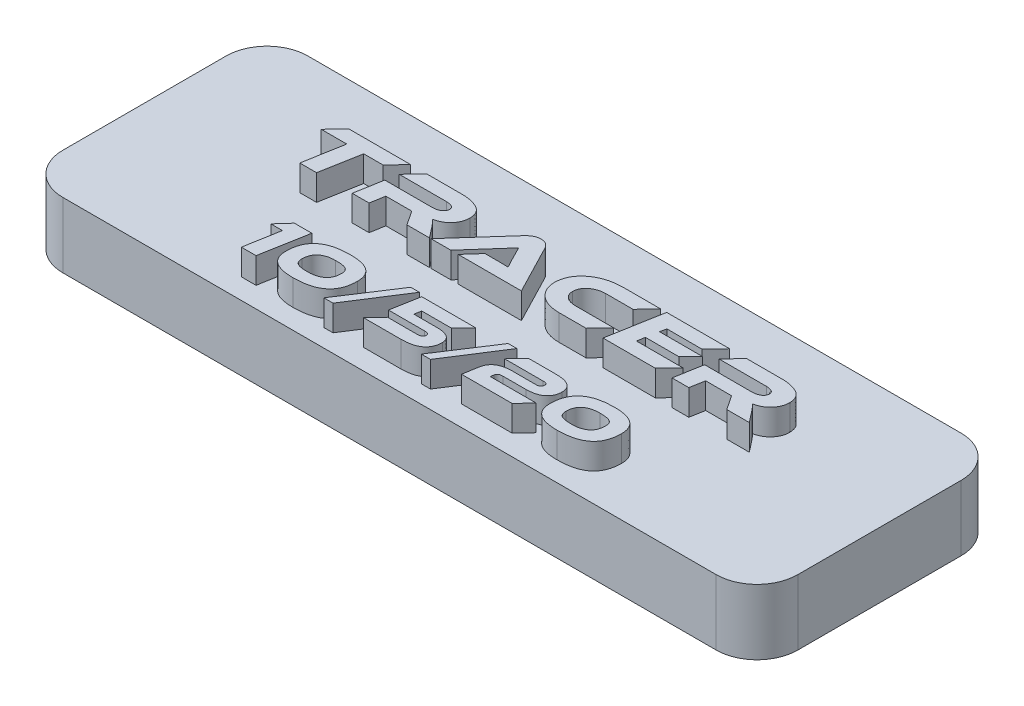
from build123d import *

# Parameters (mm, degrees)
SKETCH1_W           = 57.15
SKETCH1_H           = 19.05
BOSS_EXTRUDE1_DEPTH = 5.08
FILLET1_R           = 3.175
BOSS_EXTRUDE2_DEPTH = 2
SKETCH4_R           = 0.9
CUT_EXTRUDE1_DEPTH  = 4


with BuildPart() as part:
    # Sketch1 → Boss-Extrude1 (new body)
    with BuildSketch(Plane(origin=(0, 0, 0), x_dir=(1, 0, 0), z_dir=(0, 1, 0))):
        Rectangle(SKETCH1_W, SKETCH1_H)
    extrude(amount=BOSS_EXTRUDE1_DEPTH)

    # Fillet1
    fillet1_edges = [part.edges().sort_by_distance(p)[0] for p in [
        (-28.575, 2.54, -9.525),
        (-28.575, 2.54, 9.525),
        (28.575, 2.54, 9.525),
        (28.575, 2.54, -9.525),
    ]]
    fillet(fillet1_edges, radius=FILLET1_R)

    # Sketch3 → Boss-Extrude2 (add)
    with BuildSketch(Plane(origin=(0, 5.08, 0), x_dir=(1, 0, 0), z_dir=(0, 1, 0))):
        with BuildLine():
            add(Edge.make_bspline(
                [(17.808583065, 0.821261664), (17.780796939, 0.855514425), (17.727887369, 0.920737585), (17.654102028, 1.014147602), (17.585498843, 1.094728322), (17.525132752, 1.165931133), (17.469151617, 1.228233858), (17.417647241, 1.283693514), (17.369064358, 1.332710365), (17.336760483, 1.361916294), (17.321401159, 1.375802657)],
                knots=[0, 0, 0, 0, 0.000132319, 0.000251958, 0.000357066, 0.000449775, 0.000531993, 0.000608312, 0.000676831, 0.00073894, 0.00073894, 0.00073894, 0.00073894], degree=3))
            add(Edge.make_bspline(
                [(17.321401159, 1.375802657), (17.371846082, 1.387655917), (17.471178792, 1.41099655), (17.615145812, 1.456505146), (17.750984544, 1.512656797), (17.878954086, 1.577599655), (17.999740692, 1.650662326), (18.111465112, 1.734287933), (18.215202991, 1.827209607), (18.310758459, 1.928008098), (18.396625274, 2.036209783), (18.472838882, 2.148795776), (18.536085152, 2.26744033), (18.589751097, 2.389702633), (18.630253479, 2.517720245), (18.662407259, 2.649747841), (18.680016954, 2.787111939), (18.684148398, 2.88015474), (18.686233961, 2.927122995)],
                knots=[0, 0, 0, 0, 0.000155422, 0.000306047, 0.000452383, 0.000595882, 0.000736201, 0.000875336, 0.001013884, 0.001153561, 0.001291475, 0.00142788, 0.00156081, 0.001694289, 0.00182785, 0.001963107, 0.002101444, 0.002242464, 0.002242464, 0.002242464, 0.002242464], degree=3))
            add(Edge.make_bspline(
                [(18.686233961, 2.927122995), (18.681570314, 2.986733362), (18.672571354, 3.101757358), (18.636165187, 3.266295736), (18.583579546, 3.416602664), (18.512618081, 3.55250609), (18.424089862, 3.674215745), (18.316288118, 3.779555576), (18.192942579, 3.872802597), (18.05131082, 3.946152329), (17.901517173, 4.009923214), (17.747227802, 4.066098529), (17.589109987, 4.111445148), (17.428122354, 4.149301444), (17.263555019, 4.17747869), (17.09601278, 4.196572697), (16.925405287, 4.207081738), (16.810706728, 4.20637971), (16.752797005, 4.206025266)],
                knots=[0, 0, 0, 0, 0.000179195, 0.000345775, 0.000503934, 0.000655634, 0.000804102, 0.000953423, 0.00110627, 0.001266195, 0.001430402, 0.00159465, 0.001758393, 0.001923592, 0.002090563, 0.002258951, 0.002429281, 0.002602973, 0.002602973, 0.002602973, 0.002602973], degree=3))
            Line((16.752797005, 4.206025266), (14.03629737, 4.206347541))
            Line((14.03629737, 4.206347541), (12.987387109, 3.106887389))
            Line((12.987387109, 3.106887389), (16.664891757, 3.106887389))
            add(Edge.make_bspline(
                [(16.664891757, 3.106887389), (16.712853307, 3.105563142), (16.803665063, 3.103055777), (16.931769874, 3.084102014), (17.043390167, 3.053127658), (17.13774974, 3.008361144), (17.213916059, 2.950733271), (17.269652471, 2.878524615), (17.302879134, 2.792039639), (17.306644482, 2.729960255), (17.308602995, 2.697670193)],
                knots=[0, 0, 0, 0, 0.000143839, 0.000272348, 0.000387495, 0.000490117, 0.000583924, 0.00067132, 0.000760449, 0.00085706, 0.00085706, 0.00085706, 0.00085706], degree=3))
            add(Edge.make_bspline(
                [(17.308602995, 2.697670193), (17.306925955, 2.677195647), (17.303617965, 2.636809238), (17.290836727, 2.578009425), (17.270728249, 2.522994029), (17.243337309, 2.47158108), (17.209945932, 2.423095084), (17.168008998, 2.378841184), (17.118990862, 2.338813063), (17.045312647, 2.288346001), (16.940698269, 2.236864834), (16.803219092, 2.191707585), (16.652613655, 2.165412454), (16.54812873, 2.161339559), (16.494091256, 2.15923314)],
                knots=[0, 0, 0, 0, 6.1582e-05, 0.000121471, 0.000179891, 0.000236731, 0.000295819, 0.000355966, 0.000418937, 0.000485369, 0.000623551, 0.000766937, 0.000918284, 0.001080402, 0.001080402, 0.001080402, 0.001080402], degree=3))
            Line((16.494091256, 2.15923314), (12.816781224, 2.159459893))
            Line((12.816781224, 2.159459893), (12.437657033, 0.003655726))
            Line((12.437657033, 0.003655726), (13.74563549, 0.003655726))
            Line((13.74563549, 0.003655726), (13.941516322, 1.11686837))
            Line((13.941516322, 1.11686837), (15.950874531, 1.11686837))
            Line((15.950874531, 1.11686837), (16.696485439, 0.003655726))
            Line((16.696485439, 0.003655726), (18.446775452, 0.003655726))
            Line((18.446775452, 0.003655726), (17.808583065, 0.821261664))
        make_face()
        Polygon((8.571611573, 1.105536066), (8.672711357, 1.700326644), (11.276030798, 1.700326644), (12.185928855, 2.629107706), (8.843317243, 2.629107706), (8.931779554, 3.106887389), (11.667792461, 3.106887389), (12.710383985, 4.206347541), (7.819681928, 4.206347541), (7.067752284, 0.006075914), (11.137018595, 0.006075914), (12.173291382, 1.105536066), align=None)
        with BuildLine():
            add(Edge.make_bspline(
                [(3.820482353, 1.105536066), (3.780761323, 1.106368572), (3.703345841, 1.107991107), (3.590518754, 1.120099472), (3.484273761, 1.139341634), (3.383862171, 1.164731953), (3.289329261, 1.197730851), (3.200819168, 1.237674392), (3.118521578, 1.284870974), (3.042716275, 1.338214411), (2.975245037, 1.398892985), (2.915259867, 1.463686553), (2.864502207, 1.534061863), (2.822018426, 1.609307897), (2.789181432, 1.690172386), (2.765369619, 1.775740301), (2.750595998, 1.866215268), (2.747636192, 1.928202108), (2.746120386, 1.95994744)],
                knots=[0, 0, 0, 0, 0.000119146, 0.000232213, 0.000339979, 0.000442857, 0.0005426, 0.00063997, 0.000733741, 0.000826832, 0.000917476, 0.001005473, 0.001091233, 0.001177183, 0.0012641, 0.001352376, 0.001443149, 0.001538437, 0.001538437, 0.001538437, 0.001538437], degree=3))
            add(Edge.make_bspline(
                [(2.746120386, 1.95994744), (2.748498007, 2.00089212), (2.753181944, 2.08155355), (2.776941296, 2.199187811), (2.811422163, 2.311187764), (2.858398604, 2.41754111), (2.918527204, 2.517456178), (2.989951472, 2.612420697), (3.075122499, 2.700160835), (3.170482644, 2.782047564), (3.275509773, 2.855559397), (3.386992271, 2.920673089), (3.504905177, 2.975739929), (3.628515938, 3.021270473), (3.757976585, 3.058247704), (3.893480191, 3.084423964), (4.034988181, 3.10108536), (4.131324183, 3.104537604), (4.180428937, 3.106297295)],
                knots=[0, 0, 0, 0, 0.000122909, 0.000242131, 0.000358943, 0.000473945, 0.00058996, 0.00070807, 0.000829622, 0.000956043, 0.00108463, 0.001213669, 0.001342898, 0.001474501, 0.001608483, 0.001746351, 0.001888089, 0.00203545, 0.00203545, 0.00203545, 0.00203545], degree=3))
            Line((4.180428937, 3.106297295), (6.3037458, 3.106887389))
            Line((6.3037458, 3.106887389), (7.340018588, 4.206347541))
            Line((7.340018588, 4.206347541), (4.376531166, 4.206347541))
            add(Edge.make_bspline(
                [(4.376531166, 4.206347541), (4.274511376, 4.202700375), (4.0747035, 4.195557324), (3.781487586, 4.162353327), (3.50135048, 4.110015155), (3.234489531, 4.036172143), (2.979880771, 3.945267581), (2.73875412, 3.833094278), (2.51011283, 3.702119343), (2.331200298, 3.576781715), (2.195666357, 3.469194079), (2.101588733, 3.383435035), (2.012759192, 3.295964452), (1.929960056, 3.205335074), (1.854457159, 3.110727377), (1.783271377, 3.01426649), (1.720732933, 2.913020304), (1.66256647, 2.809716549), (1.611371146, 2.702914965), (1.567527882, 2.592415367), (1.529369475, 2.479140843), (1.495826369, 2.363167205), (1.470866325, 2.243547853), (1.450168152, 2.121372678), (1.437733491, 1.99550854), (1.433639078, 1.910604524), (1.431566087, 1.867617826)],
                knots=[0, 0, 0, 0, 0.000306166, 0.000599632, 0.000884344, 0.001160233, 0.001429449, 0.00169448, 0.001956971, 0.002218938, 0.002348999, 0.002475859, 0.002600617, 0.002722926, 0.00284385, 0.002963619, 0.003082322, 0.003200591, 0.003319167, 0.003437316, 0.003556997, 0.003677669, 0.003799234, 0.003923371, 0.004049262, 0.004178365, 0.004178365, 0.004178365, 0.004178365], degree=3))
            add(Edge.make_bspline(
                [(1.431566087, 1.867617826), (1.43456596, 1.801688472), (1.44047092, 1.671912941), (1.470921427, 1.482185543), (1.519574542, 1.301387781), (1.586380821, 1.130003576), (1.671389099, 0.967607666), (1.773923148, 0.814264123), (1.896175404, 0.671011828), (2.034406672, 0.536982875), (2.188663177, 0.415938203), (2.356222568, 0.308972587), (2.536928442, 0.218224767), (2.731158345, 0.144692398), (2.937328223, 0.084618858), (3.157163123, 0.042789332), (3.389231358, 0.013380635), (3.548654609, 0.00815489), (3.630107874, 0.005484928)],
                knots=[0, 0, 0, 0, 0.000197872, 0.000389491, 0.000575101, 0.000758611, 0.000940158, 0.001123976, 0.001310786, 0.001504088, 0.001700684, 0.001897981, 0.00209953, 0.002306142, 0.002520237, 0.002742905, 0.002976823, 0.003221191, 0.003221191, 0.003221191, 0.003221191], degree=3))
            Line((3.630107874, 0.005484928), (5.754015724, 0.006075914))
            Line((5.754015724, 0.006075914), (6.783969775, 1.105536066))
            Line((6.783969775, 1.105536066), (3.820482353, 1.105536066))
        make_face()
        with BuildLine():
            Line((0.725117419, 0.006075914), (-1.240009635, 3.800574494))
            add(Edge.make_bspline(
                [(-1.240009635, 3.800574494), (-1.258130579, 3.832806008), (-1.294089242, 3.896765269), (-1.358962932, 3.985575321), (-1.436222419, 4.0630874), (-1.521125331, 4.133983071), (-1.618931224, 4.192399523), (-1.731042374, 4.23493807), (-1.857084201, 4.260058315), (-1.945815134, 4.264204191), (-1.99194285, 4.266359469)],
                knots=[0, 0, 0, 0, 0.000110886, 0.000220038, 0.000328642, 0.000438436, 0.000551159, 0.000668641, 0.000796469, 0.000934872, 0.000934872, 0.000934872, 0.000934872], degree=3))
            add(Edge.make_bspline(
                [(-1.99194285, 4.266359469), (-2.04175451, 4.264009128), (-2.138485631, 4.259444915), (-2.278524387, 4.230967468), (-2.408802949, 4.187726952), (-2.528537824, 4.126959855), (-2.638219479, 4.055096369), (-2.741420833, 3.977511138), (-2.835727046, 3.892229282), (-2.893109549, 3.830720556), (-2.921638068, 3.800140628)],
                knots=[0, 0, 0, 0, 0.00014941, 0.000290146, 0.000427171, 0.000560039, 0.000691642, 0.000820174, 0.000947034, 0.001072464, 0.001072464, 0.001072464, 0.001072464], degree=3))
            Line((-2.921638068, 3.800140628), (-6.307636314, 0.006075914))
            Line((-6.307636314, 0.006075914), (-4.75954587, 0.006075914))
            Line((-4.75954587, 0.006075914), (-2.282601159, 2.798493231))
            Line((-2.282601159, 2.798493231), (-1.72023361, 1.696826253))
            add(Edge.make_bspline(
                [(-1.72023361, 1.696826253), (-1.693559605, 1.644325557), (-1.639043358, 1.5370248), (-1.569615017, 1.403208105), (-1.513531922, 1.297464771), (-1.472390808, 1.223921613), (-1.435986966, 1.155498073), (-1.410688661, 1.112747401), (-1.398656522, 1.092414734)],
                knots=[0, 0, 0, 0, 0.000176664, 0.000361065, 0.000452265, 0.000535729, 0.000613867, 0.000684736, 0.000684736, 0.000684736, 0.000684736], degree=3))
            add(Edge.make_bspline(
                [(-1.398656522, 1.092414734), (-1.454104866, 1.095166522), (-1.572264702, 1.101030553), (-1.756695237, 1.103502684), (-1.951714103, 1.10564963), (-2.0839667, 1.105358474), (-2.150091594, 1.105212899)],
                knots=[0, 0, 0, 0, 0.000166537, 0.000354888, 0.000553268, 0.00075164, 0.00075164, 0.00075164, 0.00075164], degree=3))
            Line((-2.150091594, 1.105212899), (-3.205136689, 1.105536066))
            Line((-3.205136689, 1.105536066), (-4.190859584, 0.006075914))
            Line((-4.190859584, 0.006075914), (0.725117419, 0.006075914))
        make_face()
        with BuildLine():
            add(Edge.make_bspline(
                [(-7.056421766, 0.821261664), (-7.084207891, 0.855514425), (-7.137117462, 0.920737585), (-7.210902803, 1.014147602), (-7.279505988, 1.094728322), (-7.339872079, 1.165931133), (-7.395853214, 1.228233858), (-7.44735759, 1.283693514), (-7.495940473, 1.332710365), (-7.528244348, 1.361916294), (-7.543603671, 1.375802657)],
                knots=[0, 0, 0, 0, 0.000132319, 0.000251958, 0.000357066, 0.000449775, 0.000531993, 0.000608312, 0.000676831, 0.00073894, 0.00073894, 0.00073894, 0.00073894], degree=3))
            add(Edge.make_bspline(
                [(-7.543603671, 1.375802657), (-7.493158749, 1.387655917), (-7.393826039, 1.41099655), (-7.249859019, 1.456505146), (-7.114020287, 1.512656797), (-6.986050744, 1.577599655), (-6.865264138, 1.650662326), (-6.753539719, 1.734287933), (-6.649801839, 1.827209607), (-6.554246372, 1.928008098), (-6.468379557, 2.036209783), (-6.392165949, 2.148795776), (-6.328919679, 2.26744033), (-6.275253734, 2.389702633), (-6.234751352, 2.517720245), (-6.202597572, 2.649747841), (-6.184987877, 2.787111939), (-6.180856433, 2.88015474), (-6.17877087, 2.927122995)],
                knots=[0, 0, 0, 0, 0.000155422, 0.000306047, 0.000452383, 0.000595882, 0.000736201, 0.000875336, 0.001013884, 0.001153561, 0.001291475, 0.00142788, 0.00156081, 0.001694289, 0.00182785, 0.001963107, 0.002101444, 0.002242464, 0.002242464, 0.002242464, 0.002242464], degree=3))
            add(Edge.make_bspline(
                [(-6.17877087, 2.927122995), (-6.183434517, 2.986733362), (-6.192433477, 3.101757358), (-6.228839644, 3.266295736), (-6.281425285, 3.416602664), (-6.35238675, 3.55250609), (-6.440914969, 3.674215745), (-6.548716712, 3.779555576), (-6.672062252, 3.872802597), (-6.813694011, 3.946152329), (-6.963487658, 4.009923214), (-7.117777029, 4.066098529), (-7.275894844, 4.111445148), (-7.436882477, 4.149301444), (-7.601449812, 4.17747869), (-7.768992051, 4.196572697), (-7.939599544, 4.207081738), (-8.054298103, 4.20637971), (-8.112207826, 4.206025266)],
                knots=[0, 0, 0, 0, 0.000179195, 0.000345775, 0.000503934, 0.000655634, 0.000804102, 0.000953423, 0.00110627, 0.001266195, 0.001430402, 0.00159465, 0.001758393, 0.001923592, 0.002090563, 0.002258951, 0.002429281, 0.002602973, 0.002602973, 0.002602973, 0.002602973], degree=3))
            Line((-8.112207826, 4.206025266), (-10.828707461, 4.206347541))
            Line((-10.828707461, 4.206347541), (-11.877617722, 3.106887389))
            Line((-11.877617722, 3.106887389), (-8.200113074, 3.106887389))
            add(Edge.make_bspline(
                [(-8.200113074, 3.106887389), (-8.152151524, 3.105563142), (-8.061339768, 3.103055777), (-7.933234957, 3.084102014), (-7.821614664, 3.053127658), (-7.727255091, 3.008361144), (-7.651088772, 2.950733271), (-7.59535236, 2.878524615), (-7.562125697, 2.792039639), (-7.558360349, 2.729960255), (-7.556401836, 2.697670193)],
                knots=[0, 0, 0, 0, 0.000143839, 0.000272348, 0.000387495, 0.000490117, 0.000583924, 0.00067132, 0.000760449, 0.00085706, 0.00085706, 0.00085706, 0.00085706], degree=3))
            add(Edge.make_bspline(
                [(-7.556401836, 2.697670193), (-7.558078875, 2.677195647), (-7.561386866, 2.636809238), (-7.574168104, 2.578009425), (-7.594276582, 2.522994029), (-7.621667522, 2.47158108), (-7.655058899, 2.423095084), (-7.696995833, 2.378841184), (-7.746013969, 2.338813063), (-7.819692184, 2.288346001), (-7.924306562, 2.236864834), (-8.061785739, 2.191707585), (-8.212391176, 2.165412454), (-8.316876101, 2.161339559), (-8.370913575, 2.15923314)],
                knots=[0, 0, 0, 0, 6.1582e-05, 0.000121471, 0.000179891, 0.000236731, 0.000295819, 0.000355966, 0.000418937, 0.000485369, 0.000623551, 0.000766937, 0.000918284, 0.001080402, 0.001080402, 0.001080402, 0.001080402], degree=3))
            Line((-8.370913575, 2.15923314), (-12.048223607, 2.159459893))
            Line((-12.048223607, 2.159459893), (-12.427347798, 0.003655726))
            Line((-12.427347798, 0.003655726), (-11.119369341, 0.003655726))
            Line((-11.119369341, 0.003655726), (-10.923488509, 1.11686837))
            Line((-10.923488509, 1.11686837), (-8.9141303, 1.11686837))
            Line((-8.9141303, 1.11686837), (-8.168519392, 0.003655726))
            Line((-8.168519392, 0.003655726), (-6.418229379, 0.003655726))
            Line((-6.418229379, 0.003655726), (-7.056421766, 0.821261664))
        make_face()
        Polygon((-16.889222079, 4.206347541), (-17.938132339, 3.106887389), (-15.954049076, 3.106887389), (-16.503779152, 0.003655726), (-15.195800695, 0.003655726), (-14.639751882, 3.106887389), (-13.135892594, 3.106887389), (-12.086982333, 4.206347541), align=None)
        with BuildLine():
            add(Edge.make_bspline(
                [(12.169570041, -4.205753245), (12.112468685, -4.20639815), (12.000136614, -4.207666832), (11.834425188, -4.213805403), (11.674414401, -4.225246011), (11.519900797, -4.240095428), (11.37100602, -4.260037206), (11.227788675, -4.284920981), (11.089877095, -4.313802188), (10.957328068, -4.346120038), (10.830514159, -4.383749272), (10.709576932, -4.426552533), (10.593554301, -4.472224962), (10.483700027, -4.524117338), (10.378631334, -4.578873484), (10.279615039, -4.638857599), (10.186140404, -4.703243715), (10.098326394, -4.771965987), (10.015468161, -4.844826576), (9.93847452, -4.922821718), (9.866909556, -5.005043307), (9.799499924, -5.090962924), (9.739391164, -5.18251662), (9.682799293, -5.277290921), (9.633633224, -5.377585075), (9.587505253, -5.480915677), (9.548631627, -5.589719203), (9.51425091, -5.702636581), (9.484439908, -5.819692193), (9.461584956, -5.941608197), (9.442985816, -6.06752364), (9.430676969, -6.198094357), (9.422126321, -6.332815699), (9.421411865, -6.424102975), (9.421048659, -6.470510423)],
                knots=[0, 0, 0, 0, 0.000171312, 0.000337012, 0.00049738, 0.000652505, 0.000802621, 0.000947932, 0.001088493, 0.001225264, 0.001357119, 0.001485126, 0.001610044, 0.001730996, 0.001849428, 0.001965345, 0.002078058, 0.002189744, 0.002299681, 0.002408844, 0.002518253, 0.002626572, 0.002736165, 0.002846598, 0.002957491, 0.003071033, 0.00318591, 0.003303822, 0.003425073, 0.003548063, 0.003675777, 0.003806785, 0.003941403, 0.004080604, 0.004080604, 0.004080604, 0.004080604], degree=3))
            add(Edge.make_bspline(
                [(9.421048659, -6.470510423), (9.422406313, -6.532725476), (9.425040053, -6.653417738), (9.450427175, -6.827938058), (9.490950393, -6.990047106), (9.547744772, -7.14024227), (9.621690482, -7.277956037), (9.712251074, -7.403136721), (9.818581385, -7.515956622), (9.941638938, -7.616000774), (10.081125233, -7.702745849), (10.235745057, -7.779438213), (10.4068577, -7.842507446), (10.593416255, -7.895609169), (10.796231665, -7.935791135), (11.014812544, -7.964127031), (11.249321424, -7.98091947), (11.410868163, -7.982880129), (11.494351268, -7.983893345)],
                knots=[0, 0, 0, 0, 0.000186545, 0.000361882, 0.000527754, 0.000687003, 0.000842323, 0.000995285, 0.001149196, 0.001306104, 0.001469661, 0.00164101, 0.001823006, 0.002015943, 0.002222385, 0.002442644, 0.002676813, 0.00292724, 0.00292724, 0.00292724, 0.00292724], degree=3))
            add(Edge.make_bspline(
                [(11.494351268, -7.983893345), (11.551148832, -7.983380019), (11.662646901, -7.98237232), (11.827237734, -7.975990544), (11.986252389, -7.965003258), (12.140107772, -7.948680913), (12.288559713, -7.929266178), (12.431198679, -7.904105738), (12.568465429, -7.875596387), (12.699967043, -7.841995411), (12.826316296, -7.804464931), (12.946853278, -7.761989808), (13.062391555, -7.715814846), (13.172186892, -7.664606669), (13.276164902, -7.608490903), (13.37508354, -7.548339608), (13.468456356, -7.483895632), (13.556165684, -7.414499954), (13.638570533, -7.341424669), (13.714571424, -7.262809113), (13.787160107, -7.18190029), (13.852689263, -7.094705032), (13.913367614, -7.003516426), (13.96977868, -6.908219643), (14.019940881, -6.808134503), (14.064878604, -6.703993625), (14.103970066, -6.595424725), (14.138640351, -6.482622195), (14.166962367, -6.364960314), (14.191198475, -6.243348255), (14.209604428, -6.117331748), (14.221979441, -5.986773695), (14.230455362, -5.851777937), (14.231187523, -5.760225753), (14.231558647, -5.713818961)],
                knots=[0, 0, 0, 0, 0.000170392, 0.000334494, 0.000494064, 0.000648473, 0.00079859, 0.000943113, 0.001082891, 0.001219081, 0.001350169, 0.001478176, 0.001602352, 0.001723304, 0.001841405, 0.001956639, 0.002070464, 0.002181522, 0.00229199, 0.002400592, 0.0025094, 0.002617866, 0.002727459, 0.002837893, 0.002949859, 0.003063082, 0.00317796, 0.003295871, 0.003416929, 0.003540857, 0.00366778, 0.003798788, 0.003934205, 0.004073405, 0.004073405, 0.004073405, 0.004073405], degree=3))
            add(Edge.make_bspline(
                [(14.231558647, -5.713818961), (14.230216992, -5.651864372), (14.227608861, -5.53142685), (14.201896297, -5.357329546), (14.162708811, -5.194951682), (14.105683344, -5.045253766), (14.032315227, -4.907894424), (13.943060126, -4.782830639), (13.83695532, -4.670804764), (13.715334516, -4.570938519), (13.576786406, -4.484275151), (13.422596711, -4.409545186), (13.252718506, -4.345204255), (13.066791105, -4.293863202), (12.864859935, -4.25419887), (12.6473983, -4.225768444), (12.413684659, -4.209016704), (12.252670788, -4.207051109), (12.169570041, -4.205753245)],
                knots=[0, 0, 0, 0, 0.000185746, 0.000361083, 0.00052676, 0.000686009, 0.000840246, 0.000992741, 0.001145521, 0.00130181, 0.001463587, 0.001634583, 0.001815083, 0.002007802, 0.002212518, 0.002431984, 0.002665356, 0.002914983, 0.002914983, 0.002914983, 0.002914983], degree=3))
        make_face()
        with BuildLine():
            add(Edge.make_bspline(
                [(11.660911752, -7.021348599), (11.614718672, -7.021854174), (11.525564137, -7.022829956), (11.396649142, -7.017591194), (11.277303679, -7.009340097), (11.16754258, -6.995853431), (11.067278538, -6.977791428), (10.976735205, -6.954558851), (10.89539598, -6.92776808), (10.823188164, -6.89577873), (10.759196802, -6.85746675), (10.705170231, -6.809228041), (10.658600519, -6.753532905), (10.622050208, -6.688452997), (10.592915143, -6.615916979), (10.573454339, -6.534816355), (10.561142184, -6.445830998), (10.56044659, -6.383634321), (10.560085278, -6.351327518)],
                knots=[0, 0, 0, 0, 0.000138565, 0.000267436, 0.000386943, 0.000497368, 0.000599032, 0.000692348, 0.000777591, 0.00085564, 0.000928899, 0.001000308, 0.001071897, 0.001145712, 0.001223247, 0.001305698, 0.001395292, 0.001492131, 0.001492131, 0.001492131, 0.001492131], degree=3))
            add(Edge.make_bspline(
                [(10.560085278, -6.351327518), (10.561622131, -6.304070169), (10.564612218, -6.212126705), (10.583274158, -6.079013736), (10.612529601, -5.954439253), (10.65434742, -5.839274516), (10.706405048, -5.731825667), (10.77161527, -5.634468641), (10.84743114, -5.545120744), (10.935376687, -5.466071948), (11.033349763, -5.395226287), (11.141952241, -5.334487382), (11.260332776, -5.283435533), (11.387926383, -5.240941797), (11.525259354, -5.208296683), (11.672129215, -5.185693562), (11.828663433, -5.170762309), (11.93638475, -5.169135367), (11.991879903, -5.16829721)],
                knots=[0, 0, 0, 0, 0.000141763, 0.000275812, 0.0004025, 0.000524963, 0.000642655, 0.000759791, 0.000875529, 0.00099331, 0.001113634, 0.001237554, 0.001365798, 0.001499859, 0.001640517, 0.001788722, 0.001945363, 0.002111808, 0.002111808, 0.002111808, 0.002111808], degree=3))
            add(Edge.make_bspline(
                [(11.991879903, -5.16829721), (12.038008552, -5.168009724), (12.127086872, -5.167454564), (12.256237185, -5.171313587), (12.375848317, -5.17974049), (12.485785403, -5.193477036), (12.586078611, -5.210588071), (12.676790366, -5.232796313), (12.757984669, -5.25982086), (12.830269457, -5.291687778), (12.89389505, -5.330152418), (12.948290416, -5.377160874), (12.993877712, -5.432670471), (13.030802255, -5.496790682), (13.05965157, -5.569240936), (13.079078595, -5.650050065), (13.091514122, -5.738759012), (13.092176501, -5.80069376), (13.092522029, -5.833001866)],
                knots=[0, 0, 0, 0, 0.00013838, 0.000267224, 0.000387529, 0.000497953, 0.000599476, 0.000692596, 0.00077784, 0.000855889, 0.000929147, 0.001000031, 0.001070493, 0.001143616, 0.001221151, 0.001303602, 0.001392403, 0.001489242, 0.001489242, 0.001489242, 0.001489242], degree=3))
            add(Edge.make_bspline(
                [(13.092522029, -5.833001866), (13.090984509, -5.880258006), (13.087993125, -5.972199119), (13.06930429, -6.105585977), (13.039943341, -6.230260661), (12.999240676, -6.346409008), (12.946238519, -6.453739693), (12.880821257, -6.551573704), (12.805177247, -6.64153852), (12.717535247, -6.721564153), (12.6191203, -6.791879743), (12.511575415, -6.854243117), (12.393026077, -6.904835069), (12.265385944, -6.947243215), (12.128190771, -6.980841995), (11.981089207, -7.004512108), (11.824198458, -7.019068958), (11.716218827, -7.020761541), (11.660911752, -7.021348599)],
                knots=[0, 0, 0, 0, 0.000141763, 0.000275812, 0.000403278, 0.000525472, 0.000644235, 0.000761371, 0.000877718, 0.000996039, 0.001116363, 0.001239983, 0.001368227, 0.001502288, 0.001643134, 0.001791467, 0.001948904, 0.002115349, 0.002115349, 0.002115349, 0.002115349], degree=3))
        make_face(mode=Mode.SUBTRACT)
        with BuildLine():
            Line((4.638273756, -5.218973535), (7.62940565, -5.218973535))
            add(Edge.make_bspline(
                [(7.62940565, -5.218973535), (7.657106564, -5.218922741), (7.708952939, -5.218827674), (7.781681941, -5.225918073), (7.843205983, -5.242216387), (7.89503652, -5.26353583), (7.935129909, -5.294908436), (7.963443909, -5.334273792), (7.980995886, -5.381008794), (7.982220586, -5.4147712), (7.982854952, -5.432259348)],
                knots=[0, 0, 0, 0, 8.3099e-05, 0.000155531, 0.000218392, 0.000273538, 0.000322508, 0.000368908, 0.000417497, 0.000469711, 0.000469711, 0.000469711, 0.000469711], degree=3))
            add(Edge.make_bspline(
                [(7.982854952, -5.432259348), (7.982215158, -5.458018948), (7.981005554, -5.506720508), (7.960443168, -5.573936821), (7.927156792, -5.630194031), (7.877943169, -5.673414306), (7.81441207, -5.704561408), (7.736677903, -5.726311626), (7.643552744, -5.738498194), (7.576551099, -5.73961472), (7.5405184, -5.740215175)],
                knots=[0, 0, 0, 0, 7.6993e-05, 0.000145564, 0.000208395, 0.000270703, 0.000339032, 0.00041902, 0.000511893, 0.000619952, 0.000619952, 0.000619952, 0.000619952], degree=3))
            Line((7.5405184, -5.740215175), (5.782754906, -5.739416071))
            add(Edge.make_bspline(
                [(5.782754906, -5.739416071), (5.72715275, -5.740560639), (5.618899588, -5.742789025), (5.460904261, -5.753609346), (5.312184902, -5.772857955), (5.172562034, -5.798779792), (5.042298836, -5.833149331), (4.921219983, -5.875619954), (4.808952603, -5.92500466), (4.705750736, -5.98174212), (4.612281539, -6.047028209), (4.527756046, -6.120143527), (4.452355437, -6.201107035), (4.386354415, -6.289606037), (4.329972841, -6.385733808), (4.282877086, -6.489539314), (4.243929723, -6.600822081), (4.226608047, -6.678800473), (4.217795006, -6.718474855)],
                knots=[0, 0, 0, 0, 0.000166829, 0.000324804, 0.000474816, 0.000616477, 0.000750546, 0.000878553, 0.001001026, 0.001118108, 0.001231277, 0.001342418, 0.001452782, 0.001562526, 0.00167296, 0.001786425, 0.001904052, 0.002025887, 0.002025887, 0.002025887, 0.002025887], degree=3))
            Line((4.217795006, -6.718474855), (4.002450895, -7.932183575))
            Line((4.002450895, -7.932183575), (7.939023739, -7.932183575))
            Line((7.939023739, -7.932183575), (8.845762428, -6.970155942))
            Line((8.845762428, -6.970155942), (5.274096617, -6.970155942))
            Line((5.274096617, -6.970155942), (5.323856667, -6.707239748))
            add(Edge.make_bspline(
                [(5.323856667, -6.707239748), (5.327634191, -6.686112106), (5.334956948, -6.645156023), (5.363668301, -6.590591717), (5.402028994, -6.543848716), (5.453368325, -6.508043577), (5.514443792, -6.47963759), (5.586761412, -6.461031101), (5.669824833, -6.450993538), (5.728748343, -6.450679637), (5.759973798, -6.450513291)],
                knots=[0, 0, 0, 0, 6.4036e-05, 0.000124134, 0.000182613, 0.000243892, 0.000310094, 0.000383827, 0.000466868, 0.000560486, 0.000560486, 0.000560486, 0.000560486], degree=3))
            Line((5.759973798, -6.450513291), (7.518827761, -6.449714187))
            add(Edge.make_bspline(
                [(7.518827761, -6.449714187), (7.584508786, -6.448593152), (7.711843226, -6.446419826), (7.895741076, -6.426694059), (8.067157686, -6.400940141), (8.225004572, -6.361961645), (8.370758566, -6.315052912), (8.502099821, -6.255202462), (8.621572936, -6.187512089), (8.726285376, -6.107690588), (8.818868568, -6.020066732), (8.899324929, -5.925525662), (8.967103814, -5.823724541), (9.022856616, -5.715194429), (9.064992585, -5.599220599), (9.095688021, -5.476792913), (9.113343366, -5.347458364), (9.11529632, -5.259004345), (9.116292373, -5.21389067)],
                knots=[0, 0, 0, 0, 0.00019697, 0.000381861, 0.000554393, 0.000716581, 0.000869107, 0.001013024, 0.00114885, 0.001280192, 0.001406932, 0.001530654, 0.001651783, 0.001773055, 0.001895792, 0.002021116, 0.002151095, 0.002286391, 0.002286391, 0.002286391, 0.002286391], degree=3))
            add(Edge.make_bspline(
                [(9.116292373, -5.21389067), (9.115839918, -5.1780961), (9.114954174, -5.108023129), (9.098744326, -5.005989197), (9.074752254, -4.909275966), (9.038217551, -4.818686266), (8.990583198, -4.734234215), (8.932504156, -4.655338408), (8.864136529, -4.582231577), (8.784842089, -4.515185386), (8.694019172, -4.455053695), (8.590440552, -4.402688892), (8.474207431, -4.359688685), (8.346019952, -4.322394884), (8.205216943, -4.294289614), (8.051869897, -4.27367202), (7.886003367, -4.26108405), (7.771173751, -4.258543735), (7.711693847, -4.257227893)],
                knots=[0, 0, 0, 0, 0.000107259, 0.000209975, 0.000309113, 0.00040566, 0.000501999, 0.00059927, 0.000698874, 0.0008016, 0.000910084, 0.001024914, 0.001148961, 0.001281358, 0.001425053, 0.00157924, 0.00174531, 0.001923772, 0.001923772, 0.001923772, 0.001923772], degree=3))
            Line((7.711693847, -4.257227893), (5.545012445, -4.256945902))
            Line((5.545012445, -4.256945902), (4.638273756, -5.218973535))
        make_face()
        Polygon((3.752463315, -4.05005839), (1.087536193, -8.139071868), (1.800763576, -8.139071868), (4.426988437, -4.05005839), align=None)
        with BuildLine():
            Line((-2.761314859, -4.256945902), (-3.153866364, -6.449714187))
            Line((-3.153866364, -6.449714187), (-0.334130198, -6.449714187))
            add(Edge.make_bspline(
                [(-0.334130198, -6.449714187), (-0.306723808, -6.450617634), (-0.255385686, -6.452309987), (-0.183552876, -6.461034695), (-0.122750608, -6.47794104), (-0.071814466, -6.500188686), (-0.032873186, -6.531757828), (-0.004004341, -6.569480873), (0.011263963, -6.6155469), (0.012798562, -6.647983764), (0.01359805, -6.664882542)],
                knots=[0, 0, 0, 0, 8.2264e-05, 0.000154098, 0.000216396, 0.000271146, 0.000319491, 0.000365246, 0.00041179, 0.000462411, 0.000462411, 0.000462411, 0.000462411], degree=3))
            add(Edge.make_bspline(
                [(0.01359805, -6.664882542), (0.013100214, -6.689261699), (0.012158462, -6.735379606), (-0.006404581, -6.800600698), (-0.041381944, -6.855321695), (-0.091398087, -6.899490615), (-0.155754079, -6.933442043), (-0.234478397, -6.955421351), (-0.32694358, -6.969012009), (-0.393220499, -6.969940912), (-0.428738502, -6.970438714)],
                knots=[0, 0, 0, 0, 7.2948e-05, 0.000137995, 0.00020057, 0.000265138, 0.000335999, 0.000416981, 0.000509176, 0.000615636, 0.000615636, 0.000615636, 0.000615636], degree=3))
            Line((-0.428738502, -6.970438714), (-2.706025914, -6.970155942))
            Line((-2.706025914, -6.970155942), (-3.607235709, -7.932183575))
            Line((-3.607235709, -7.932183575), (-0.682450548, -7.932183575))
            add(Edge.make_bspline(
                [(-0.682450548, -7.932183575), (-0.604236932, -7.9303287), (-0.453200951, -7.926746807), (-0.235345935, -7.906904388), (-0.034433328, -7.874908226), (0.149724036, -7.83285179), (0.316700999, -7.777247216), (0.466893585, -7.711378043), (0.600568146, -7.633963557), (0.715530427, -7.543208912), (0.815460619, -7.443844467), (0.90214503, -7.337601683), (0.974920862, -7.223789253), (1.033379325, -7.102808547), (1.079572403, -6.975361392), (1.110165452, -6.84019725), (1.129537509, -6.698518397), (1.130001624, -6.6014906), (1.13023788, -6.55209872)],
                knots=[0, 0, 0, 0, 0.000234661, 0.000453147, 0.000655662, 0.000844638, 0.00101917, 0.001182821, 0.001335919, 0.00148121, 0.001620915, 0.001757957, 0.001891758, 0.002025195, 0.002160303, 0.002297478, 0.002440248, 0.002588281, 0.002588281, 0.002588281, 0.002588281], degree=3))
            add(Edge.make_bspline(
                [(1.13023788, -6.55209872), (1.129004205, -6.519527164), (1.126605385, -6.456193431), (1.112579179, -6.364135406), (1.087057404, -6.278812601), (1.054254528, -6.198734636), (1.008793406, -6.126044171), (0.95563339, -6.058385444), (0.891141513, -5.998122221), (0.81806001, -5.943422007), (0.735177814, -5.895579182), (0.643328098, -5.854246138), (0.543238206, -5.817937937), (0.433627523, -5.789532319), (0.315214554, -5.767332235), (0.187784838, -5.751620251), (0.051344941, -5.741887844), (-0.042643358, -5.740784853), (-0.09118692, -5.740215175)],
                knots=[0, 0, 0, 0, 9.7747e-05, 0.000190063, 0.000278402, 0.000364423, 0.000448791, 0.000534736, 0.000621869, 0.000712736, 0.000808084, 0.000908309, 0.001014576, 0.001127107, 0.00124759, 0.001375774, 0.001512093, 0.001657707, 0.001657707, 0.001657707, 0.001657707], degree=3))
            Line((-0.09118692, -5.740215175), (-1.887749537, -5.739416071))
            Line((-1.887749537, -5.739416071), (-1.799287226, -5.218973535))
            Line((-1.799287226, -5.218973535), (0.511790652, -5.218973535))
            Line((0.511790652, -5.218973535), (1.424058235, -4.256945902))
            Line((1.424058235, -4.256945902), (-2.761314859, -4.256945902))
        make_face()
        Polygon((-3.824049922, -4.05005839), (-6.488977044, -8.139071868), (-5.77574966, -8.139071868), (-3.1495248, -4.05005839), align=None)
        with BuildLine():
            add(Edge.make_bspline(
                [(-8.358685418, -4.205753245), (-8.415786774, -4.20639815), (-8.528118845, -4.207666832), (-8.693830271, -4.213805403), (-8.853841058, -4.225246011), (-9.008354662, -4.240095428), (-9.157249439, -4.260037206), (-9.300466784, -4.284920981), (-9.438378364, -4.313802188), (-9.570927391, -4.346120038), (-9.6977413, -4.383749272), (-9.818678527, -4.426552533), (-9.934701158, -4.472224962), (-10.044555432, -4.524117338), (-10.149624125, -4.578873484), (-10.24864042, -4.638857599), (-10.342115055, -4.703243715), (-10.429929065, -4.771965987), (-10.512787298, -4.844826576), (-10.589780939, -4.922821718), (-10.661345903, -5.005043307), (-10.728755535, -5.090962924), (-10.788864295, -5.18251662), (-10.845456166, -5.277290921), (-10.894622234, -5.377585075), (-10.940750206, -5.480915677), (-10.979623831, -5.589719203), (-11.014004549, -5.702636581), (-11.043815551, -5.819692193), (-11.066670503, -5.941608197), (-11.085269642, -6.06752364), (-11.09757849, -6.198094357), (-11.106129138, -6.332815699), (-11.106843594, -6.424102975), (-11.1072068, -6.470510423)],
                knots=[0, 0, 0, 0, 0.000171312, 0.000337012, 0.00049738, 0.000652505, 0.000802621, 0.000947932, 0.001088493, 0.001225264, 0.001357119, 0.001485126, 0.001610044, 0.001730996, 0.001849428, 0.001965345, 0.002078058, 0.002189744, 0.002299681, 0.002408844, 0.002518253, 0.002626572, 0.002736165, 0.002846598, 0.002957491, 0.003071033, 0.00318591, 0.003303822, 0.003425073, 0.003548063, 0.003675777, 0.003806785, 0.003941403, 0.004080604, 0.004080604, 0.004080604, 0.004080604], degree=3))
            add(Edge.make_bspline(
                [(-11.1072068, -6.470510423), (-11.105849146, -6.532725476), (-11.103215406, -6.653417738), (-11.077828284, -6.827938058), (-11.037305066, -6.990047106), (-10.980510687, -7.14024227), (-10.906564977, -7.277956037), (-10.816004385, -7.403136721), (-10.709674074, -7.515956622), (-10.586616521, -7.616000774), (-10.447130226, -7.702745849), (-10.292510402, -7.779438213), (-10.121397759, -7.842507446), (-9.934839203, -7.895609169), (-9.732023794, -7.935791135), (-9.513442915, -7.964127031), (-9.278934035, -7.98091947), (-9.117387296, -7.982880129), (-9.033904191, -7.983893345)],
                knots=[0, 0, 0, 0, 0.000186545, 0.000361882, 0.000527754, 0.000687003, 0.000842323, 0.000995285, 0.001149196, 0.001306104, 0.001469661, 0.00164101, 0.001823006, 0.002015943, 0.002222385, 0.002442644, 0.002676813, 0.00292724, 0.00292724, 0.00292724, 0.00292724], degree=3))
            add(Edge.make_bspline(
                [(-9.033904191, -7.983893345), (-8.977106627, -7.983380019), (-8.865608558, -7.98237232), (-8.701017725, -7.975990544), (-8.54200307, -7.965003258), (-8.388147686, -7.948680913), (-8.239695746, -7.929266178), (-8.09705678, -7.904105738), (-7.95979003, -7.875596387), (-7.828288416, -7.841995411), (-7.701939163, -7.804464931), (-7.581402181, -7.761989808), (-7.465863903, -7.715814846), (-7.356068567, -7.664606669), (-7.252090557, -7.608490903), (-7.153171919, -7.548339608), (-7.059799103, -7.483895632), (-6.972089775, -7.414499954), (-6.889684926, -7.341424669), (-6.813684035, -7.262809113), (-6.741095352, -7.18190029), (-6.675566196, -7.094705032), (-6.614887845, -7.003516426), (-6.558476779, -6.908219643), (-6.508314578, -6.808134503), (-6.463376855, -6.703993625), (-6.424285393, -6.595424725), (-6.389615108, -6.482622195), (-6.361293092, -6.364960314), (-6.337056984, -6.243348255), (-6.318651031, -6.117331748), (-6.306276018, -5.986773695), (-6.297800097, -5.851777937), (-6.297067936, -5.760225753), (-6.296696812, -5.713818961)],
                knots=[0, 0, 0, 0, 0.000170392, 0.000334494, 0.000494064, 0.000648473, 0.00079859, 0.000943113, 0.001082891, 0.001219081, 0.001350169, 0.001478176, 0.001602352, 0.001723304, 0.001841405, 0.001956639, 0.002070464, 0.002181522, 0.00229199, 0.002400592, 0.0025094, 0.002617866, 0.002727459, 0.002837893, 0.002949859, 0.003063082, 0.00317796, 0.003295871, 0.003416929, 0.003540857, 0.00366778, 0.003798788, 0.003934205, 0.004073405, 0.004073405, 0.004073405, 0.004073405], degree=3))
            add(Edge.make_bspline(
                [(-6.296696812, -5.713818961), (-6.298038467, -5.651864372), (-6.300646598, -5.53142685), (-6.326359162, -5.357329546), (-6.365546648, -5.194951682), (-6.422572115, -5.045253766), (-6.495940232, -4.907894424), (-6.585195333, -4.782830639), (-6.691300139, -4.670804764), (-6.812920943, -4.570938519), (-6.951469053, -4.484275151), (-7.105658748, -4.409545186), (-7.275536953, -4.345204255), (-7.461464354, -4.293863202), (-7.663395524, -4.25419887), (-7.880857159, -4.225768444), (-8.1145708, -4.209016704), (-8.275584671, -4.207051109), (-8.358685418, -4.205753245)],
                knots=[0, 0, 0, 0, 0.000185746, 0.000361083, 0.00052676, 0.000686009, 0.000840246, 0.000992741, 0.001145521, 0.00130181, 0.001463587, 0.001634583, 0.001815083, 0.002007802, 0.002212518, 0.002431984, 0.002665356, 0.002914983, 0.002914983, 0.002914983, 0.002914983], degree=3))
        make_face()
        with BuildLine():
            add(Edge.make_bspline(
                [(-8.867343707, -7.021348599), (-8.913536787, -7.021854174), (-9.002691322, -7.022829956), (-9.131606317, -7.017591194), (-9.25095178, -7.009340097), (-9.360712879, -6.995853431), (-9.460976921, -6.977791428), (-9.551520254, -6.954558851), (-9.632859479, -6.92776808), (-9.705067295, -6.89577873), (-9.769058657, -6.85746675), (-9.823085228, -6.809228041), (-9.86965494, -6.753532905), (-9.906205251, -6.688452997), (-9.935340316, -6.615916979), (-9.95480112, -6.534816355), (-9.967113275, -6.445830998), (-9.967808869, -6.383634321), (-9.968170181, -6.351327518)],
                knots=[0, 0, 0, 0, 0.000138565, 0.000267436, 0.000386943, 0.000497368, 0.000599032, 0.000692348, 0.000777591, 0.00085564, 0.000928899, 0.001000308, 0.001071897, 0.001145712, 0.001223247, 0.001305698, 0.001395292, 0.001492131, 0.001492131, 0.001492131, 0.001492131], degree=3))
            add(Edge.make_bspline(
                [(-9.968170181, -6.351327518), (-9.966633328, -6.304070169), (-9.963643241, -6.212126705), (-9.944981301, -6.079013736), (-9.915725858, -5.954439253), (-9.873908039, -5.839274516), (-9.821850411, -5.731825667), (-9.756640189, -5.634468641), (-9.680824319, -5.545120744), (-9.592878772, -5.466071948), (-9.494905696, -5.395226287), (-9.386303218, -5.334487382), (-9.267922682, -5.283435533), (-9.140329076, -5.240941797), (-9.002996105, -5.208296683), (-8.856126244, -5.185693562), (-8.699592026, -5.170762309), (-8.591870709, -5.169135367), (-8.536375556, -5.16829721)],
                knots=[0, 0, 0, 0, 0.000141763, 0.000275812, 0.0004025, 0.000524963, 0.000642655, 0.000759791, 0.000875529, 0.00099331, 0.001113634, 0.001237554, 0.001365798, 0.001499859, 0.001640517, 0.001788722, 0.001945363, 0.002111808, 0.002111808, 0.002111808, 0.002111808], degree=3))
            add(Edge.make_bspline(
                [(-8.536375556, -5.16829721), (-8.490246906, -5.168009724), (-8.401168586, -5.167454564), (-8.272018274, -5.171313587), (-8.152407142, -5.17974049), (-8.042470056, -5.193477036), (-7.942176848, -5.210588071), (-7.851465092, -5.232796313), (-7.77027079, -5.25982086), (-7.697986002, -5.291687778), (-7.634360409, -5.330152418), (-7.579965043, -5.377160874), (-7.534377747, -5.432670471), (-7.497453204, -5.496790682), (-7.468603889, -5.569240936), (-7.449176864, -5.650050065), (-7.436741337, -5.738759012), (-7.436078958, -5.80069376), (-7.43573343, -5.833001866)],
                knots=[0, 0, 0, 0, 0.00013838, 0.000267224, 0.000387529, 0.000497953, 0.000599476, 0.000692596, 0.00077784, 0.000855889, 0.000929147, 0.001000031, 0.001070493, 0.001143616, 0.001221151, 0.001303602, 0.001392403, 0.001489242, 0.001489242, 0.001489242, 0.001489242], degree=3))
            add(Edge.make_bspline(
                [(-7.43573343, -5.833001866), (-7.43727095, -5.880258006), (-7.440262334, -5.972199119), (-7.458951169, -6.105585977), (-7.488312118, -6.230260661), (-7.529014783, -6.346409008), (-7.58201694, -6.453739693), (-7.647434202, -6.551573704), (-7.723078212, -6.64153852), (-7.810720212, -6.721564153), (-7.909135159, -6.791879743), (-8.016680044, -6.854243117), (-8.135229382, -6.904835069), (-8.262869515, -6.947243215), (-8.400064688, -6.980841995), (-8.547166252, -7.004512108), (-8.704057001, -7.019068958), (-8.812036631, -7.020761541), (-8.867343707, -7.021348599)],
                knots=[0, 0, 0, 0, 0.000141763, 0.000275812, 0.000403278, 0.000525472, 0.000644235, 0.000761371, 0.000877718, 0.000996039, 0.001116363, 0.001239983, 0.001368227, 0.001502288, 0.001643134, 0.001791467, 0.001948904, 0.002115349, 0.002115349, 0.002115349, 0.002115349], degree=3))
        make_face(mode=Mode.SUBTRACT)
        Polygon((-13.530620126, -5.218973535), (-12.629410332, -5.218973535), (-13.110424149, -7.93430124), (-11.965942999, -7.93430124), (-11.30800456, -4.256945902), (-12.662583699, -4.256945902), align=None)
    extrude(amount=BOSS_EXTRUDE2_DEPTH)

    # Sketch4 → Cut-Extrude1 (cut)
    with BuildSketch(Plane.XZ):
        with Locations((-25.4, 0)):
            Circle(SKETCH4_R)
        with Locations((25.4, 0)):
            Circle(SKETCH4_R)
    extrude(amount=-CUT_EXTRUDE1_DEPTH, mode=Mode.SUBTRACT)


solid = part.part
